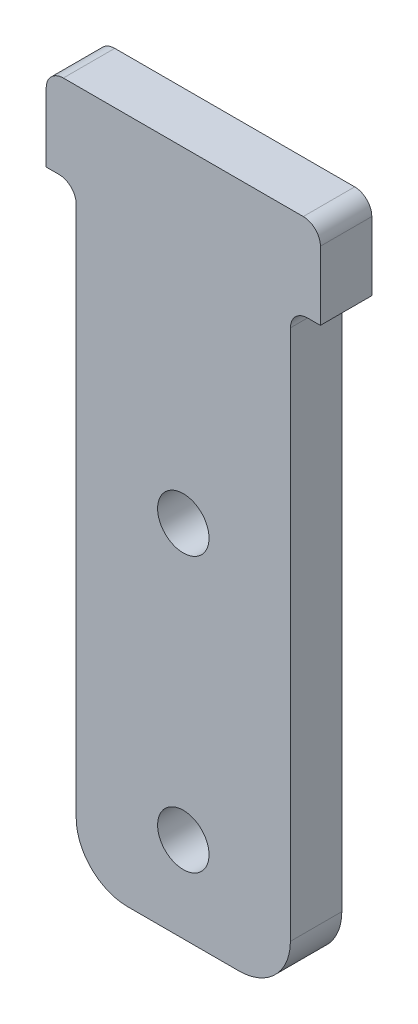
from build123d import *

# Parameters (mm, degrees)
SKETCH1_R           = 1.5
BOSS_EXTRUDE1_DEPTH = 3
FILLET1_R           = 1
FILLET2_R           = 3


with BuildPart() as part:
    # Sketch1 → Boss-Extrude1 (new body)
    with BuildSketch(Plane.XY):
        Polygon((6.25, 17.5), (8, 17.5), (8, 22.5), (-8, 22.5), (-8, 17.5), (-6.25, 17.5), (-6.25, -17.5), (6.25, -17.5), align=None)
        with Locations((0, 3.5)):
            Circle(SKETCH1_R, mode=Mode.SUBTRACT)
        with Locations((0, -12.5)):
            Circle(SKETCH1_R, mode=Mode.SUBTRACT)
    extrude(amount=BOSS_EXTRUDE1_DEPTH)

    # Fillet1
    fillet1_edges = [part.edges().sort_by_distance(p)[0] for p in [
        (6.25, 17.5, 1.5),
        (-6.25, 17.5, 1.5),
        (-8, 22.5, 1.5),
        (8, 22.5, 1.5),
    ]]
    fillet(fillet1_edges, radius=FILLET1_R)

    # Fillet2
    fillet2_edges = [part.edges().sort_by_distance(p)[0] for p in [
        (6.25, -17.5, 1.5),
        (-6.25, -17.5, 1.5),
    ]]
    fillet(fillet2_edges, radius=FILLET2_R)


solid = part.part
